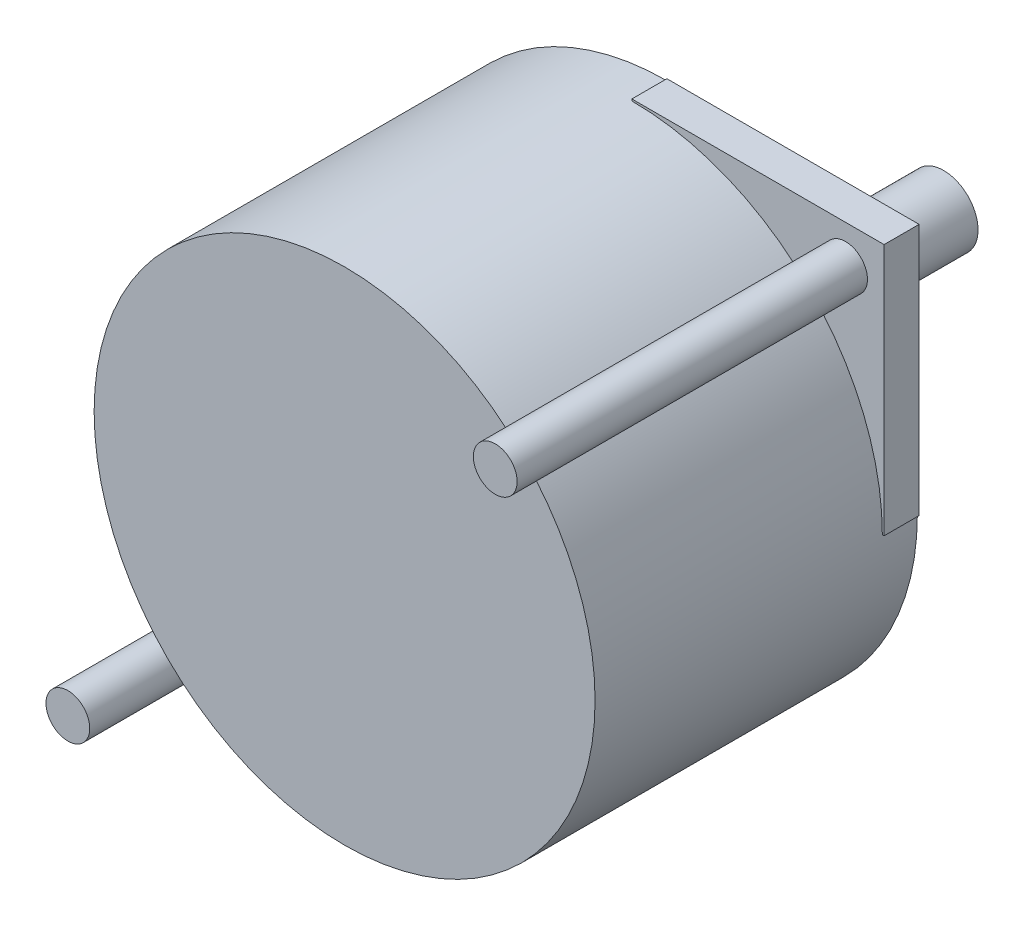
from build123d import *

# Parameters (mm, degrees)
SKETCH1_W           = 36.576
SKETCH1_H           = 36.576
BOSS_EXTRUDE1_DEPTH = 2.54
SKETCH2_R           = 1.5875
BOSS_EXTRUDE2_DEPTH = 25.4
CUT_EXTRUDE4_DEPTH  = 3.54
SKETCH4_R           = 8.001
BOSS_EXTRUDE3_DEPTH = 1.016
SKETCH5_R           = 2.49555
BOSS_EXTRUDE4_DEPTH = 19.05
SKETCH6_R           = 18.161
BOSS_EXTRUDE5_DEPTH = 20.828


with BuildPart() as part:
    # Sketch1 → Boss-Extrude1 (new body)
    with BuildSketch(Plane.XY):
        with Locations((17.649916168, -17.343808383)):
            Rectangle(SKETCH1_W, SKETCH1_H)
    extrude(amount=BOSS_EXTRUDE1_DEPTH)

    # Sketch2 → Boss-Extrude2 (add)
    with BuildSketch(Plane.XY.offset(2.54)):
        with Locations((33.143916168, -1.849808383)):
            Circle(SKETCH2_R)
        with Locations((2.155916168, -32.837808383)):
            Circle(SKETCH2_R)
    extrude(amount=BOSS_EXTRUDE2_DEPTH)

    # Sketch3 → Cut-Extrude4 (cut, through all)
    with BuildSketch(Plane.XY.offset(2.54)):
        with BuildLine():
            Line((-0.638083832, 0.944191617), (-0.638083832, -17.343808383))
            Line((-0.638083832, -17.343808383), (-0.511083832, -17.343808383))
            ThreePointArc((-0.511083832, -17.343808383), (4.808149915, -4.50204213), (17.649916168, 0.817191617))
            Line((17.649916168, 0.817191617), (17.649916168, 0.944191617))
            Line((17.649916168, 0.944191617), (-0.638083832, 0.944191617))
        make_face()
        with BuildLine():
            Line((35.937916168, -35.631808383), (17.649916168, -35.631808383))
            Line((17.649916168, -35.631808383), (17.649916168, -35.504808383))
            ThreePointArc((17.649916168, -35.504808383), (30.491682421, -30.185574636), (35.810916168, -17.343808383))
            Line((35.810916168, -17.343808383), (35.937916168, -17.343808383))
            Line((35.937916168, -17.343808383), (35.937916168, -35.631808383))
        make_face()
    extrude(amount=-CUT_EXTRUDE4_DEPTH, mode=Mode.SUBTRACT)

    # Sketch4 → Boss-Extrude3 (add)
    with BuildSketch(Plane(origin=(0, 0, 0), x_dir=(-1, 0, 0), z_dir=(0, 0, -1))):
        with Locations((-17.649916168, -17.343808383)):
            Circle(SKETCH4_R)
    extrude(amount=BOSS_EXTRUDE3_DEPTH)

    # Sketch5 → Boss-Extrude4 (add)
    with BuildSketch(Plane(origin=(0, 0, -1.016), x_dir=(-1, 0, 0), z_dir=(0, 0, -1))):
        with Locations((-17.649916168, -17.343808383)):
            Circle(SKETCH5_R)
    extrude(amount=BOSS_EXTRUDE4_DEPTH)

    # Sketch6 → Boss-Extrude5 (add)
    with BuildSketch(Plane.XY.offset(2.54)):
        with Locations((17.649916168, -17.343808383)):
            Circle(SKETCH6_R)
    extrude(amount=BOSS_EXTRUDE5_DEPTH)


solid = part.part
